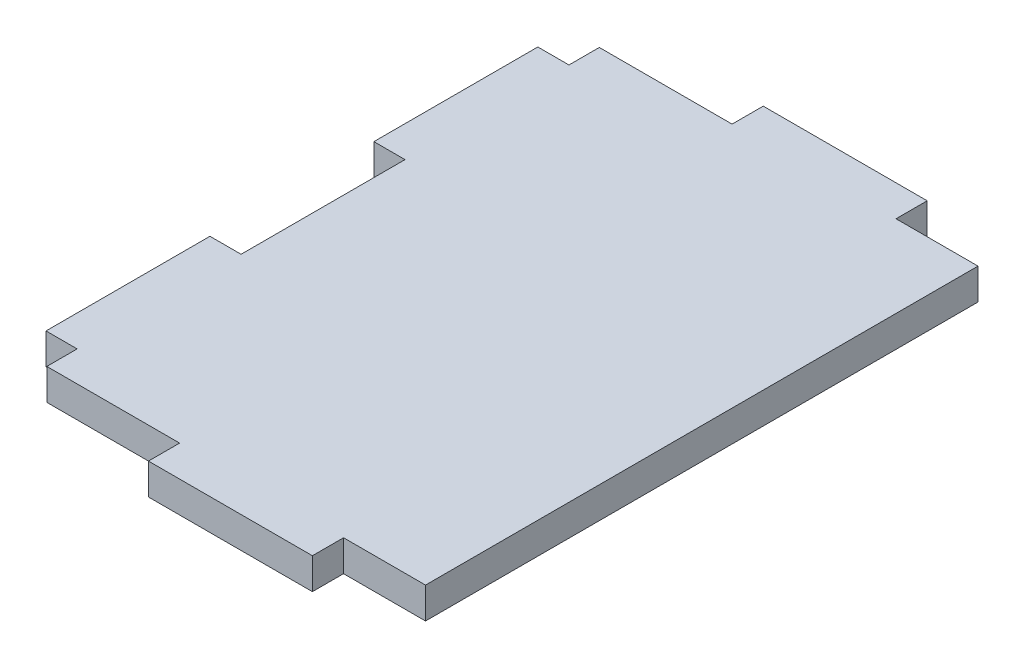
from build123d import *

# Parameters (mm, degrees)
BOSS_EXTRUDE1_DEPTH = 4.826


with BuildPart() as part:
    # Sketch1 → Boss-Extrude1 (new body)
    with BuildSketch(Plane(origin=(0, 0, 0), x_dir=(1, 0, 0), z_dir=(0, 1, 0))):
        Polygon((4.826, 60.325), (4.826, 34.925), (0, 34.925), (0, 9.525), (4.826, 9.525), (4.826, 4.826), (25.4, 4.826), (25.4, 0), (50.8, 0), (50.8, 4.826), (63.5, 4.826), (63.5, 90.424), (50.8, 90.424), (50.8, 95.25), (25.4, 95.25), (25.4, 90.424), (4.826, 90.424), (4.826, 85.725), (0, 85.725), (0, 60.325), align=None)
    extrude(amount=BOSS_EXTRUDE1_DEPTH)


solid = part.part
